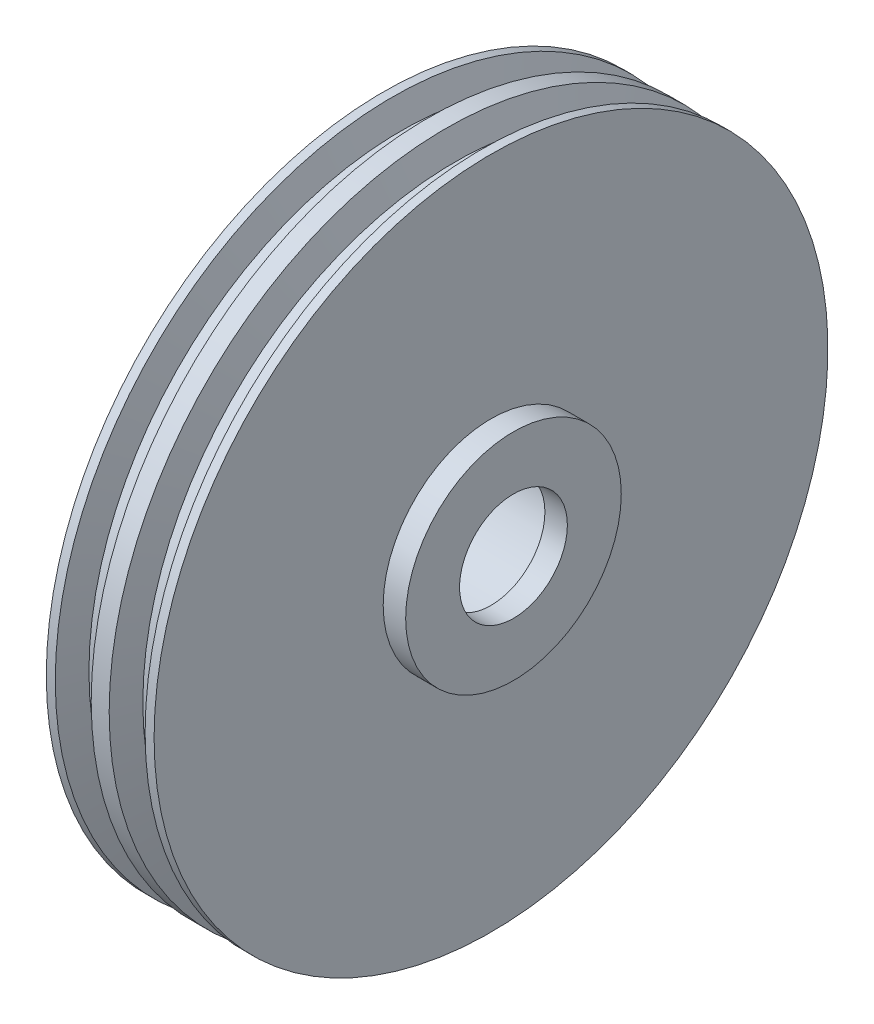
from build123d import *

# Parameters (mm, degrees)
SKETCH2_R           = 9.52900057
CUT_EXTRUDE2_DEPTH  = 62
SKETCH3_R           = 12
SKETCH3_R_2         = 6
BOSS_EXTRUDE1_DEPTH = 2.5


with BuildPart() as part:
    # Sketch1 → Revolve1 (revolve)
    with BuildSketch(Plane.XY):
        Polygon((0, 0), (0, 37.5), (1, 37.5), (2, 34.752522581), (4, 34.752522581), (5, 37.5), (6, 37.5), (6, 0), align=None)
    revolve(axis=Axis((0, 0, 0), (1, 0, 0)))

    # Sketch2 → Cut-Extrude2 (cut)
    with BuildSketch(Plane(origin=(6, 0, 0), x_dir=(0, 0, -1), z_dir=(1, 0, 0))):
        Circle(SKETCH2_R)
    extrude(amount=-CUT_EXTRUDE2_DEPTH, mode=Mode.SUBTRACT)

    # Sketch3 → Boss-Extrude1 (add)
    with BuildSketch(Plane(origin=(6, 0, 0), x_dir=(0, 0, -1), z_dir=(1, 0, 0))):
        Circle(SKETCH3_R)
        Circle(SKETCH3_R_2, mode=Mode.SUBTRACT)
    extrude(amount=BOSS_EXTRUDE1_DEPTH)

    # Mirror1: part across plane


with BuildPart() as part_1:
    add(part.part)
    add(part.part.mirror(Plane(origin=(0, 0, 0), x_dir=(0, 0, 1), z_dir=(1, 0, 0))))


solid = part_1.part
